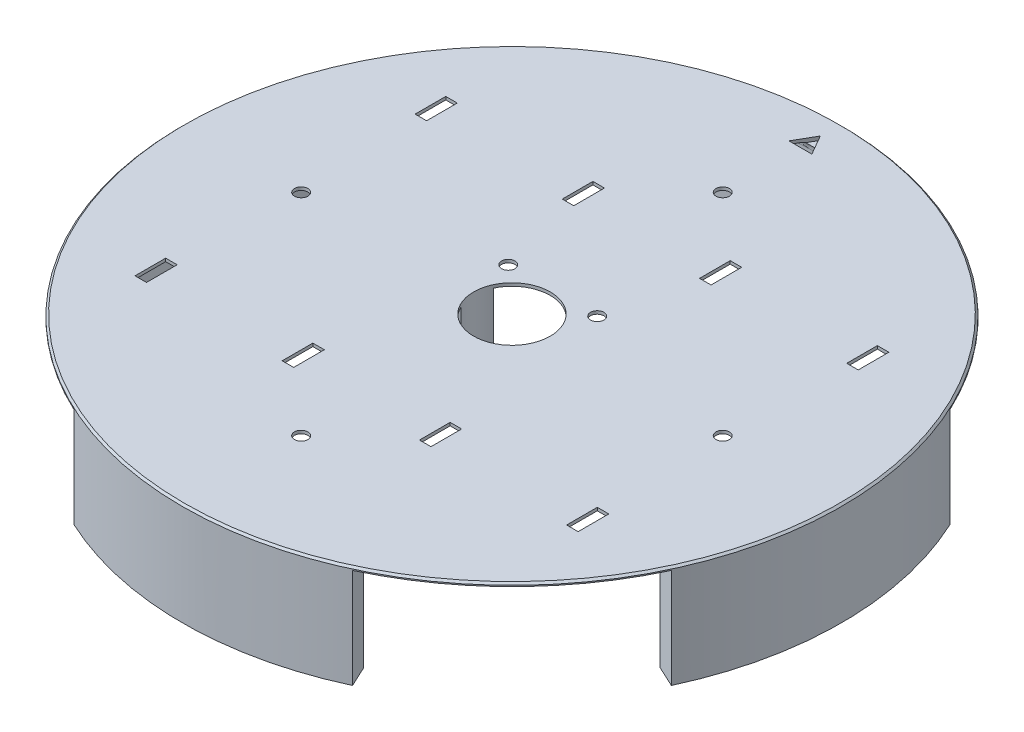
from build123d import *
from build123d.topology import SkipClean

# Parameters (mm, degrees)
SKIZZE1_R                       = 86
AUFSATZ_LINEAR_AUSTRAGEN1_DEPTH = 0.8
AUFSATZ_LINEAR_START            = 26
AUFSATZ_LINEAR_AUSTRAGEN2_DEPTH = 26
KREISMUSTER1_COUNT              = 4
SCHNITT_LINEAR_AUSTRAGEN1_REACH = 126.37
SKIZZE4_R                       = 10
AUFSATZ_LINEAR_AUSTRAGEN5_DEPTH = 26
SKIZZE6_R                       = 1.35
SCHNITT_LINEAR_AUSTRAGEN2_DEPTH = 10
KREISMUSTER2_COUNT              = 4
VERRUNDUNG3_R                   = 3
SCHNITT_LINEAR_AUSTRAGEN4_REACH = 126.37
SKIZZE10_W                      = 3
SKIZZE10_H                      = 8
FASE1_SIZE                      = 0.5
SCHNITT_LINEAR_AUSTRAGEN5_DEPTH = 1
SKIZZE12_R                      = 1.75
SCHNITT_LINEAR_AUSTRAGEN6_DEPTH = 5


with BuildPart() as part:
    # Skizze1 → Aufsatz-Linear austragen1 (new body)
    with BuildSketch(Plane(origin=(0, 0, 0), x_dir=(1, 0, 0), z_dir=(0, 1, 0))):
        with Locations(Location((0, 0, 0), (0, 0, 270))):
            Circle(SKIZZE1_R)
    extrude(amount=AUFSATZ_LINEAR_AUSTRAGEN1_DEPTH)

    # Skizze2 → Aufsatz-Linear austragen2 (add)
    with SkipClean():  # the faces are left unmerged after this step: merging them gives an invalid solid
        with BuildSketch(Plane.XZ.offset(AUFSATZ_LINEAR_START)):
            with BuildLine():
                Line((-36.345171, 77.94247), (-33.809461, 72.504623))
                ThreePointArc((-33.809461, 72.504623), (0, 80), (33.809461, 72.504623))
                Line((33.809461, 72.504623), (36.345171, 77.94247))
                ThreePointArc((36.345171, 77.94247), (0, 86), (-36.345171, 77.94247))
            make_face()
        aufsatz_linear_austragen2 = extrude(amount=-AUFSATZ_LINEAR_AUSTRAGEN2_DEPTH)

    # Kreismuster1: Aufsatz-Linear austragen2 ×4 about axis
    with SkipClean():  # the faces are left unmerged after this step: merging them gives an invalid solid
        kreismuster1_axis = Axis((0, -99.932475, 0), (0, 1, 0))
        for i in range(1, KREISMUSTER1_COUNT):
            add(aufsatz_linear_austragen2.rotate(kreismuster1_axis, i * 360 / KREISMUSTER1_COUNT))

    # Skizze4 → Schnitt-Linear austragen1 (cut, up to next)
    with BuildSketch(Plane.XZ, mode=Mode.PRIVATE) as schnitt_linear_austragen1_sk1:
        with Locations(Location((0, 0, 0), (0, 0, 270))):
            Circle(SKIZZE4_R)
    schnitt_linear_austragen1_tool1 = extrude(schnitt_linear_austragen1_sk1.sketch, amount=-SCHNITT_LINEAR_AUSTRAGEN1_REACH, mode=Mode.PRIVATE) & part.part
    add(schnitt_linear_austragen1_tool1.solids().sort_by_distance((0, 0, 0))[0], mode=Mode.SUBTRACT)

    # Skizze7 → Aufsatz-Linear austragen5 (add)
    with SkipClean():  # the faces are left unmerged after this step: merging them gives an invalid solid
        with BuildSketch(Plane.XZ.offset(AUFSATZ_LINEAR_START)):
            with BuildLine():
                Line((-9.063078, 4.226183), (-11.782001, 5.494037))
                ThreePointArc((-11.782001, 5.494037), (-13, 0), (-11.782001, -5.494037))
                Line((-11.782001, -5.494037), (-9.063078, -4.226183))
                ThreePointArc((-9.063078, -4.226183), (-10, 0), (-9.063078, 4.226183))
            make_face()
            with BuildLine():
                ThreePointArc((13, 0), (12.691848, 2.813715), (11.782001, 5.494037))
                Line((11.782001, 5.494037), (9.063078, 4.226183))
                ThreePointArc((9.063078, 4.226183), (9.76296, 2.164396), (10, 0))
                ThreePointArc((10, 0), (9.76296, -2.164396), (9.063078, -4.226183))
                Line((9.063078, -4.226183), (11.782001, -5.494037))
                ThreePointArc((11.782001, -5.494037), (12.691848, -2.813715), (13, 0))
            make_face()
        extrude(amount=-AUFSATZ_LINEAR_AUSTRAGEN5_DEPTH)

    # Skizze6 → Schnitt-Linear austragen2 (cut)
    with SkipClean():  # the faces are left unmerged after this step: merging them gives an invalid solid
        with BuildSketch(Plane.XZ.offset(26)):
            with Locations(Location((-21.456083, 80.075191, 0), (0, 0, 270))):
                Circle(SKIZZE6_R)
            with Locations(Location((21.456083, 80.075191, 0), (0, 0, 270))):
                Circle(SKIZZE6_R)
        schnitt_linear_austragen2 = extrude(amount=-SCHNITT_LINEAR_AUSTRAGEN2_DEPTH, mode=Mode.SUBTRACT)

    # Kreismuster2: Schnitt-Linear austragen2 ×4 about axis
    with SkipClean():  # the faces are left unmerged after this step: merging them gives an invalid solid
        kreismuster2_axis = Axis((0, 0, 0), (0, 1, 0))
        for i in range(1, KREISMUSTER2_COUNT):
            add(schnitt_linear_austragen2.rotate(kreismuster2_axis, i * 360 / KREISMUSTER2_COUNT), mode=Mode.SUBTRACT)

    # Verrundung3
    verrundung3_edges = [part.edges().sort_by_distance(p)[0] for p in [
        (80, 0, 0),
        (0, 0, -80),
        (-80, 0, 0),
        (-13, 0, 0),
        (13, 0, 0),
        (0, 0, 80),
    ]]
    fillet(verrundung3_edges, radius=VERRUNDUNG3_R)

    # Skizze10 → Schnitt-Linear austragen4 (cut, up to next)
    with BuildSketch(Plane.XZ, mode=Mode.PRIVATE) as schnitt_linear_austragen4_sk1:
        with Locations((56.312567, 36.541606)):
            Rectangle(SKIZZE10_W, SKIZZE10_H)
    schnitt_linear_austragen4_tool1 = extrude(schnitt_linear_austragen4_sk1.sketch, amount=-SCHNITT_LINEAR_AUSTRAGEN4_REACH, mode=Mode.PRIVATE) & part.part
    # Skizze10 → Schnitt-Linear austragen4 (cut, up to next)
    with BuildSketch(Plane.XZ, mode=Mode.PRIVATE) as schnitt_linear_austragen4_sk2:
        with Locations((17.912567, 36.541606)):
            Rectangle(SKIZZE10_W, SKIZZE10_H)
    schnitt_linear_austragen4_tool2 = extrude(schnitt_linear_austragen4_sk2.sketch, amount=-SCHNITT_LINEAR_AUSTRAGEN4_REACH, mode=Mode.PRIVATE) & part.part
    # Skizze10 → Schnitt-Linear austragen4 (cut, up to next)
    with BuildSketch(Plane.XZ, mode=Mode.PRIVATE) as schnitt_linear_austragen4_sk3:
        with Locations((-17.912567, 36.541606)):
            Rectangle(SKIZZE10_W, SKIZZE10_H)
    schnitt_linear_austragen4_tool3 = extrude(schnitt_linear_austragen4_sk3.sketch, amount=-SCHNITT_LINEAR_AUSTRAGEN4_REACH, mode=Mode.PRIVATE) & part.part
    # Skizze10 → Schnitt-Linear austragen4 (cut, up to next)
    with BuildSketch(Plane.XZ, mode=Mode.PRIVATE) as schnitt_linear_austragen4_sk4:
        with Locations((-56.312567, 36.541606)):
            Rectangle(SKIZZE10_W, SKIZZE10_H)
    schnitt_linear_austragen4_tool4 = extrude(schnitt_linear_austragen4_sk4.sketch, amount=-SCHNITT_LINEAR_AUSTRAGEN4_REACH, mode=Mode.PRIVATE) & part.part
    # Skizze10 → Schnitt-Linear austragen4 (cut, up to next)
    with BuildSketch(Plane.XZ, mode=Mode.PRIVATE) as schnitt_linear_austragen4_sk5:
        with Locations((56.312567, -36.541606)):
            Rectangle(SKIZZE10_W, SKIZZE10_H)
    schnitt_linear_austragen4_tool5 = extrude(schnitt_linear_austragen4_sk5.sketch, amount=-SCHNITT_LINEAR_AUSTRAGEN4_REACH, mode=Mode.PRIVATE) & part.part
    # Skizze10 → Schnitt-Linear austragen4 (cut, up to next)
    with BuildSketch(Plane.XZ, mode=Mode.PRIVATE) as schnitt_linear_austragen4_sk6:
        with Locations((17.912567, -36.541606)):
            Rectangle(SKIZZE10_W, SKIZZE10_H)
    schnitt_linear_austragen4_tool6 = extrude(schnitt_linear_austragen4_sk6.sketch, amount=-SCHNITT_LINEAR_AUSTRAGEN4_REACH, mode=Mode.PRIVATE) & part.part
    # Skizze10 → Schnitt-Linear austragen4 (cut, up to next)
    with BuildSketch(Plane.XZ, mode=Mode.PRIVATE) as schnitt_linear_austragen4_sk7:
        with Locations((-17.912567, -36.541606)):
            Rectangle(SKIZZE10_W, SKIZZE10_H)
    schnitt_linear_austragen4_tool7 = extrude(schnitt_linear_austragen4_sk7.sketch, amount=-SCHNITT_LINEAR_AUSTRAGEN4_REACH, mode=Mode.PRIVATE) & part.part
    # Skizze10 → Schnitt-Linear austragen4 (cut, up to next)
    with BuildSketch(Plane.XZ, mode=Mode.PRIVATE) as schnitt_linear_austragen4_sk8:
        with Locations((-56.312567, -36.541606)):
            Rectangle(SKIZZE10_W, SKIZZE10_H)
    schnitt_linear_austragen4_tool8 = extrude(schnitt_linear_austragen4_sk8.sketch, amount=-SCHNITT_LINEAR_AUSTRAGEN4_REACH, mode=Mode.PRIVATE) & part.part
    add(schnitt_linear_austragen4_tool1.solids().sort_by_distance((56.312567, 0, 36.541606))[0], mode=Mode.SUBTRACT)
    add(schnitt_linear_austragen4_tool2.solids().sort_by_distance((17.912567, 0, 36.541606))[0], mode=Mode.SUBTRACT)
    add(schnitt_linear_austragen4_tool3.solids().sort_by_distance((-17.912567, 0, 36.541606))[0], mode=Mode.SUBTRACT)
    add(schnitt_linear_austragen4_tool4.solids().sort_by_distance((-56.312567, 0, 36.541606))[0], mode=Mode.SUBTRACT)
    add(schnitt_linear_austragen4_tool5.solids().sort_by_distance((56.312567, 0, -36.541606))[0], mode=Mode.SUBTRACT)
    add(schnitt_linear_austragen4_tool6.solids().sort_by_distance((17.912567, 0, -36.541606))[0], mode=Mode.SUBTRACT)
    add(schnitt_linear_austragen4_tool7.solids().sort_by_distance((-17.912567, 0, -36.541606))[0], mode=Mode.SUBTRACT)
    add(schnitt_linear_austragen4_tool8.solids().sort_by_distance((-56.312567, 0, -36.541606))[0], mode=Mode.SUBTRACT)

    # Fase1
    fase1_edges = [part.edges().sort_by_distance(p)[0] for p in [
        (0, 0.8, -86),
    ]]
    chamfer(fase1_edges, length=FASE1_SIZE)

    # Skizze11 → Schnitt-Linear austragen5 (cut)
    with SkipClean():  # the faces are left unmerged after this step: merging them gives an invalid solid
        with BuildSketch(Plane(origin=(0, 0.8, 0), x_dir=(1, 0, 0), z_dir=(0, 1, 0))):
            Polygon((3, 75.267949), (0, 80.464102), (-3, 75.267949), align=None)
        extrude(amount=-SCHNITT_LINEAR_AUSTRAGEN5_DEPTH, mode=Mode.SUBTRACT)

    # Skizze12 → Schnitt-Linear austragen6 (cut)
    with SkipClean():  # the faces are left unmerged after this step: merging them gives an invalid solid
        with BuildSketch(Plane.XZ):
            with Locations(Location((-55, 0, 0), (0, 0, 270))):
                Circle(SKIZZE12_R)
            with Locations(Location((0, -55, 0), (0, 0, 270))):
                Circle(SKIZZE12_R)
            with Locations(Location((55, 0, 0), (0, 0, 270))):
                Circle(SKIZZE12_R)
            with Locations(Location((0, 55, 0), (0, 0, 270))):
                Circle(SKIZZE12_R)
            with Locations(Location((-11.605237, -10.644187, 0), (0, 0, 270))):
                Circle(SKIZZE12_R)
            with Locations(Location((11.605237, -10.644187, 0), (0, 0, 270))):
                Circle(SKIZZE12_R)
        extrude(amount=-SCHNITT_LINEAR_AUSTRAGEN6_DEPTH, mode=Mode.SUBTRACT)


solid = part.part
